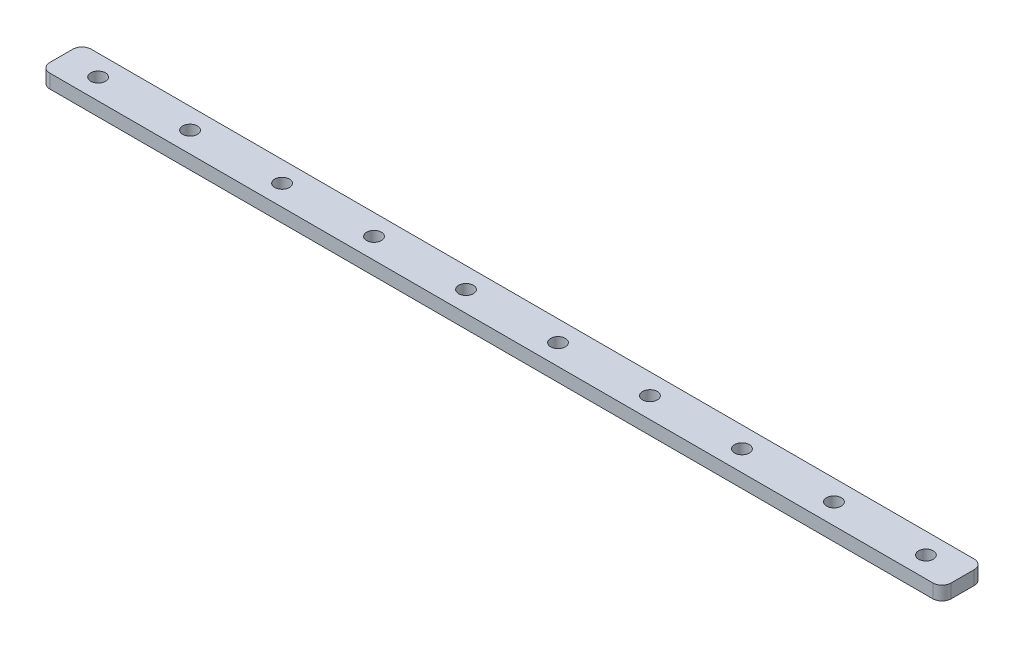
from build123d import *

# Parameters (mm, degrees)
SKETCH_1_W      = 196
SKETCH_1_H      = 9
SKETCH_1_R      = 1.6
EXTRUDE_1_DEPTH = 3
FILLET_1_R      = 2


with BuildPart() as part:
    # 草图1 → 凸台-拉伸1 (new body)
    with BuildSketch(Plane(origin=(0, 0, 0), x_dir=(1, 0, 0), z_dir=(0, 1, 0))):
        with Locations((98, 4.5)):
            Rectangle(SKETCH_1_W, SKETCH_1_H)
        with Locations((8, 4.5)):
            Circle(SKETCH_1_R, mode=Mode.SUBTRACT)
        with Locations((28, 4.5)):
            Circle(SKETCH_1_R, mode=Mode.SUBTRACT)
        with Locations((48, 4.5)):
            Circle(SKETCH_1_R, mode=Mode.SUBTRACT)
        with Locations((68, 4.5)):
            Circle(SKETCH_1_R, mode=Mode.SUBTRACT)
        with Locations((88, 4.5)):
            Circle(SKETCH_1_R, mode=Mode.SUBTRACT)
        with Locations((108, 4.5)):
            Circle(SKETCH_1_R, mode=Mode.SUBTRACT)
        with Locations((128, 4.5)):
            Circle(SKETCH_1_R, mode=Mode.SUBTRACT)
        with Locations((148, 4.5)):
            Circle(SKETCH_1_R, mode=Mode.SUBTRACT)
        with Locations((168, 4.5)):
            Circle(SKETCH_1_R, mode=Mode.SUBTRACT)
        with Locations((188, 4.5)):
            Circle(SKETCH_1_R, mode=Mode.SUBTRACT)
    extrude(amount=EXTRUDE_1_DEPTH)

    # 圆角1
    fillet_1_edges = [part.edges().sort_by_distance(p)[0] for p in [
        (0, 1.5, -9),
        (196, 1.5, -9),
        (196, 1.5, 0),
        (0, 1.5, 0),
    ]]
    fillet(fillet_1_edges, radius=FILLET_1_R)


solid = part.part
